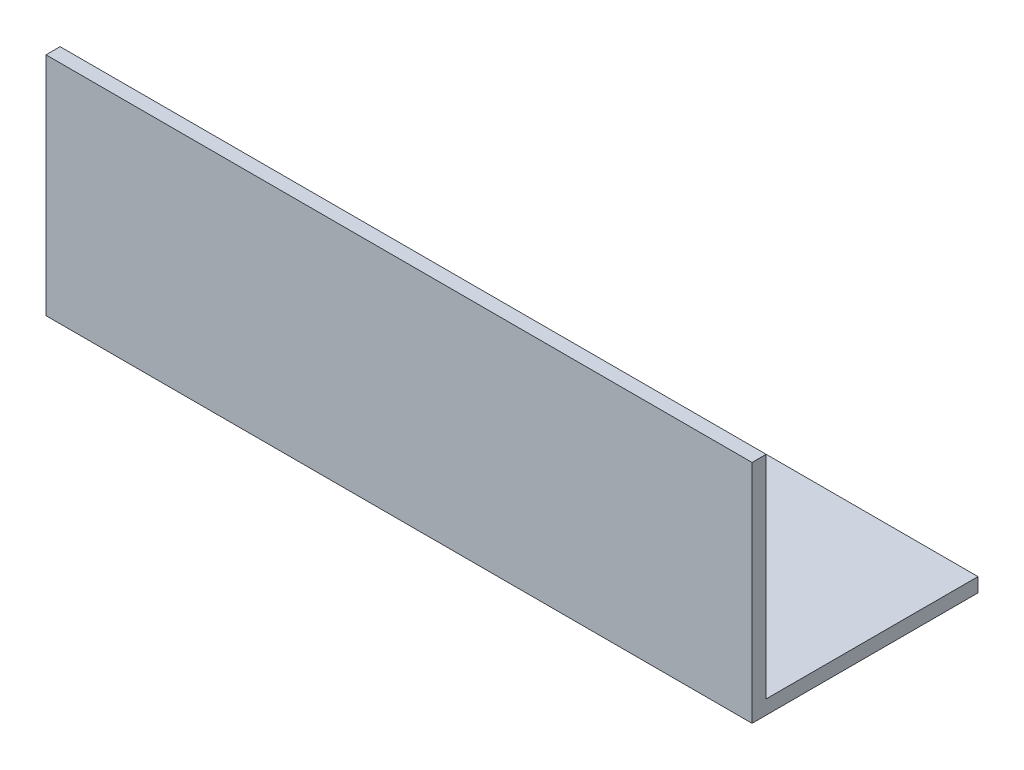
from build123d import *

# Parameters (mm, degrees)
EXTRUDE_1_DEPTH = 150


with BuildPart() as part:
    # Эскиз1 → Вытянуть-Тонкостенный1 (new body)
    with BuildSketch(Plane(origin=(0, 0, 0), x_dir=(0, 0, -1), z_dir=(1, 0, 0))):
        Polygon((0, 45), (0, 0), (45, 0), (45, -3), (-3, -3), (-3, 45), align=None)
    extrude(amount=EXTRUDE_1_DEPTH)


solid = part.part
